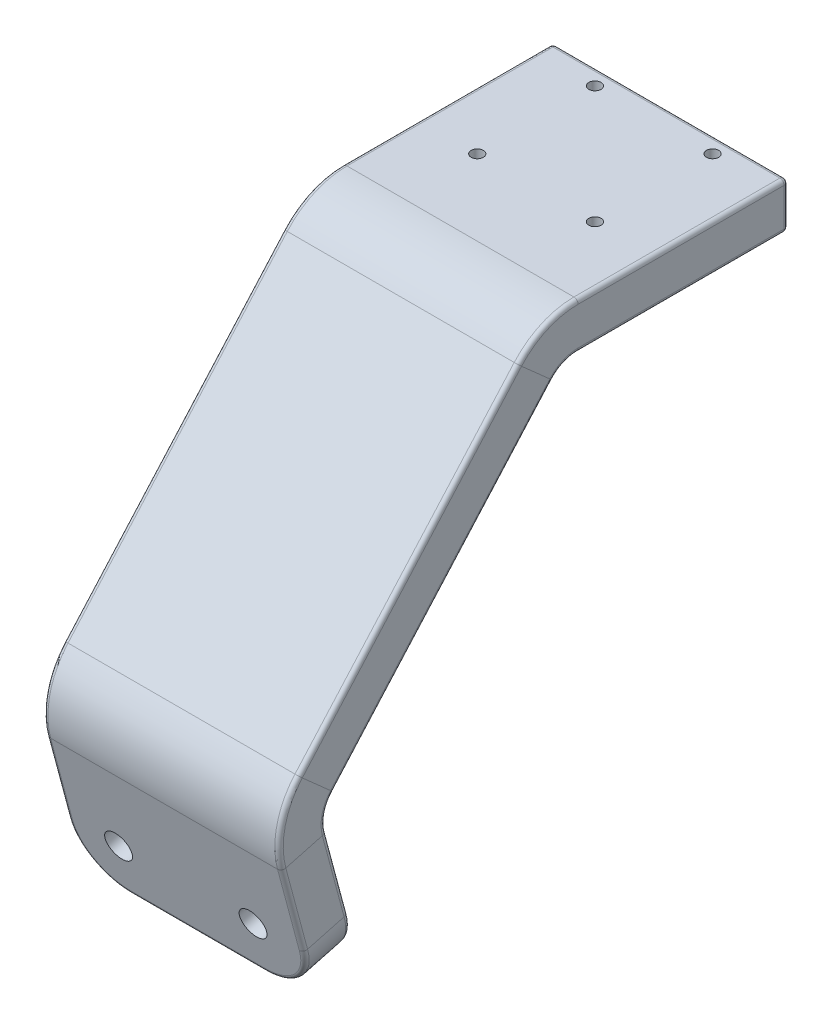
from build123d import *

# Parameters (mm, degrees)
BOSS_EXTRUDE1_DEPTH                                = 4.365625
SKETCH3_W                                          = 44.45
SKETCH3_H                                          = 8.73125
FILLET3_R                                          = 9.525
FILLET2_R                                          = 0.79375
CSK_FOR_10_FLAT_HEAD_MACHINE_SCREW_100_D           = 5.1054
CSK_FOR_10_FLAT_HEAD_MACHINE_SCREW_100_CSINK_D     = 9.779
CSK_FOR_10_FLAT_HEAD_MACHINE_SCREW_100_CSINK_ANGLE = 100
CSK_FOR_10_FLAT_HEAD_MACHINE_SCREW_2_D             = 5.1054
CSK_FOR_10_FLAT_HEAD_MACHINE_SCREW_2_CSINK_D       = 9.779
CSK_FOR_10_FLAT_HEAD_MACHINE_SCREW_2_CSINK_ANGLE   = 100
SKETCH6_R                                          = 1.15
CUT_EXTRUDE1_DEPTH                                 = 90.9706
SKETCH7_R                                          = 1.905
CUT_EXTRUDE2_DEPTH                                 = 6.35
CIRPATTERN1_COUNT                                  = 4


with BuildPart() as part:
    # Sketch1 → Boss-Extrude1 (new body, symmetric)
    with BuildSketch(Plane(origin=(0, 0, 0), x_dir=(1, 0, 0), z_dir=(0, 1, 0))):
        Polygon((-22.225, 9.525), (-22.225, -25.4), (0, -25.4), (0, -12.7), (0, 14.2875), (-17.4625, 14.2875), (-22.225, 14.2875), align=None)
    boss_extrude1 = extrude(amount=BOSS_EXTRUDE1_DEPTH, both=True)

    # Mirror1: Boss-Extrude1 across plane
    add(boss_extrude1.mirror(Plane(origin=(0, 4.365625, 25.4), x_dir=(0, 0, 1), z_dir=(-1, 0, 0))))

    # Sweep1: sweep along a path in Sketch2
    with BuildLine(Plane(origin=(0, 0, 0), x_dir=(0, 0, -1), z_dir=(1, 0, 0))) as sweep1_path:
        Line((-66.368982, -83.523553), (-72.942986, -58.989037))
        ThreePointArc((-72.942986, -58.989037), (-72.98896, -55.884372), (-71.5574, -53.12907))
        Line((-71.5574, -53.12907), (-30.148043, -6.499159))
        ThreePointArc((-30.148043, -6.499159), (-28.002685, -4.923516), (-25.4, -4.365625))
    # Sketch3 → Sweep1 (sweep)
    with BuildSketch(Plane.XY.offset(25.4)):
        Rectangle(SKETCH3_W, SKETCH3_H)
    sweep(path=sweep1_path.line)

    # Fillet3
    fillet3_edges = [part.edges().sort_by_distance(p)[0] for p in [
        (-22.225, -84.65346, 70.585852),
        (22.225, -84.65346, 70.585852),
    ]]
    fillet(fillet3_edges, radius=FILLET3_R)

    # Fillet2
    fillet2_edges = [part.edges().sort_by_distance(p)[0] for p in [
        (-22.225, 0, -14.2875),
        (-22.225, 4.365625, 5.55625),
        (22.225, 4.365625, 5.55625),
        (22.225, 0, -14.2875),
        (22.225, -4.365625, 5.55625),
        (-22.225, -4.923516, 28.002685),
        (22.225, -4.923516, 28.002685),
        (22.225, 3.040634, 31.581378),
        (-22.225, 3.040634, 31.581378),
        (-22.225, -29.814115, 50.852722),
        (22.225, -29.814115, 50.852722),
        (22.225, -24.016474, 57.381282),
        (-22.225, -24.016474, 57.381282),
        (-22.225, -55.884372, 72.98896),
        (22.225, -55.884372, 72.98896),
        (22.225, -53.875272, 81.485915),
        (-22.225, -53.875272, 81.485915),
        (-22.225, -66.656073, 70.88861),
        (22.225, -66.656073, 70.88861),
        (22.225, -68.915887, 79.32235),
        (-22.225, -68.915887, 79.32235),
        (0, -83.523553, 66.368982),
        (0, -85.783366, 74.802722),
        (-19.435192, -83.088619, 75.524777),
        (19.435192, -83.088619, 75.524777),
        (-19.435192, -80.828805, 67.091038),
        (19.435192, -80.828805, 67.091038),
        (-22.225, -4.365625, 5.55625),
        (0, 4.365625, -14.2875),
        (0, -4.365625, -14.2875),
    ]]
    fillet(fillet2_edges, radius=FILLET2_R)

    # CSK for _10 Flat Head Machine Screw _100 (through all)
    with Locations(Plane(origin=(-12.7, -74.323109, 68.834233), x_dir=(0, -0.965926, -0.258819), z_dir=(0, 0.258819, -0.965926))):
        with Locations((0, 0)):
            CounterSinkHole(CSK_FOR_10_FLAT_HEAD_MACHINE_SCREW_100_D / 2, CSK_FOR_10_FLAT_HEAD_MACHINE_SCREW_100_CSINK_D / 2, counter_sink_angle=CSK_FOR_10_FLAT_HEAD_MACHINE_SCREW_100_CSINK_ANGLE)

    # CSK for _10 Flat Head Machine Screw  2 (through all)
    with Locations(Plane(origin=(12.7, -74.323109, 68.834233), x_dir=(0, -0.965926, -0.258819), z_dir=(0, 0.258819, -0.965926))):
        with Locations((0, 0)):
            CounterSinkHole(CSK_FOR_10_FLAT_HEAD_MACHINE_SCREW_2_D / 2, CSK_FOR_10_FLAT_HEAD_MACHINE_SCREW_2_CSINK_D / 2, counter_sink_angle=CSK_FOR_10_FLAT_HEAD_MACHINE_SCREW_2_CSINK_ANGLE)

    # Sketch6 → Cut-Extrude1 (cut, through all)
    with BuildSketch(Plane(origin=(0, 4.365625, 0), x_dir=(1, 0, 0), z_dir=(0, 1, 0))):
        with Locations((-11.1125, 11.1125)):
            Circle(SKETCH6_R)
    cut_extrude1 = extrude(amount=-CUT_EXTRUDE1_DEPTH, mode=Mode.SUBTRACT)

    # Sketch7 → Cut-Extrude2 (cut)
    with BuildSketch(Plane.XZ.offset(4.365625)):
        with Locations((-11.1125, -11.1125)):
            Circle(SKETCH7_R)
    cut_extrude2 = extrude(amount=-CUT_EXTRUDE2_DEPTH, mode=Mode.SUBTRACT)

    # CirPattern1: Cut-Extrude1, Cut-Extrude2 ×4 about axis
    cirpattern1_axis = Axis((0, 0, 0), (0, 1, 0))
    for i in range(1, CIRPATTERN1_COUNT):
        add(cut_extrude1.rotate(cirpattern1_axis, i * 360 / CIRPATTERN1_COUNT), mode=Mode.SUBTRACT)
        add(cut_extrude2.rotate(cirpattern1_axis, i * 360 / CIRPATTERN1_COUNT), mode=Mode.SUBTRACT)


solid = part.part
